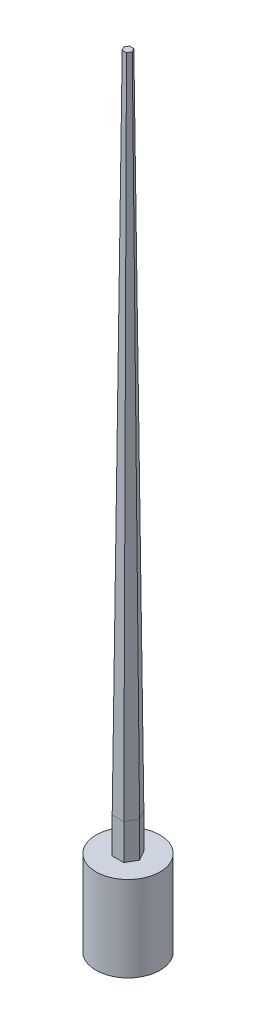
from build123d import *

# Parameters (mm, degrees)
SALIENTE_EXTRUIR1_DEPTH = 11000
SALIENTE_EXTRUIR1_TAPER = 0.55
CROQUIS2_R              = 450
SALIENTE_EXTRUIR2_DEPTH = 1700
CROQUIS3_R              = 466.892947344
CORTAR_EXTRUIR1_DEPTH   = 500


with BuildPart() as part:
    # Croquis1 → Saliente-Extruir1 (new body)
    with BuildSketch(Plane(origin=(0, 0, 0), x_dir=(1, 0, 0), z_dir=(0, 1, 0))):
        Polygon((181.865334795, 0), (90.932667397, 157.5), (-90.932667397, 157.5), (-181.865334795, 0), (-90.932667397, -157.5), (90.932667397, -157.5), align=None)
    extrude(amount=SALIENTE_EXTRUIR1_DEPTH, taper=SALIENTE_EXTRUIR1_TAPER)

    # Croquis2 → Saliente-Extruir2 (add)
    with BuildSketch(Plane.XZ):
        Circle(CROQUIS2_R)
    extrude(amount=-SALIENTE_EXTRUIR2_DEPTH)

    # Croquis3 → Cortar-Extruir1 (cut)
    with BuildSketch(Plane(origin=(0, 1700, 0), x_dir=(1, 0, 0), z_dir=(0, 1, 0))):
        Circle(CROQUIS3_R)
        Polygon((163.021395927, 0), (81.510697963, -141.180670233), (-81.510697963, -141.180670233), (-163.021395927, 0), (-81.510697963, 141.180670233), (81.510697963, 141.180670233), align=None, mode=Mode.SUBTRACT)
    extrude(amount=-CORTAR_EXTRUIR1_DEPTH, mode=Mode.SUBTRACT)


solid = part.part
